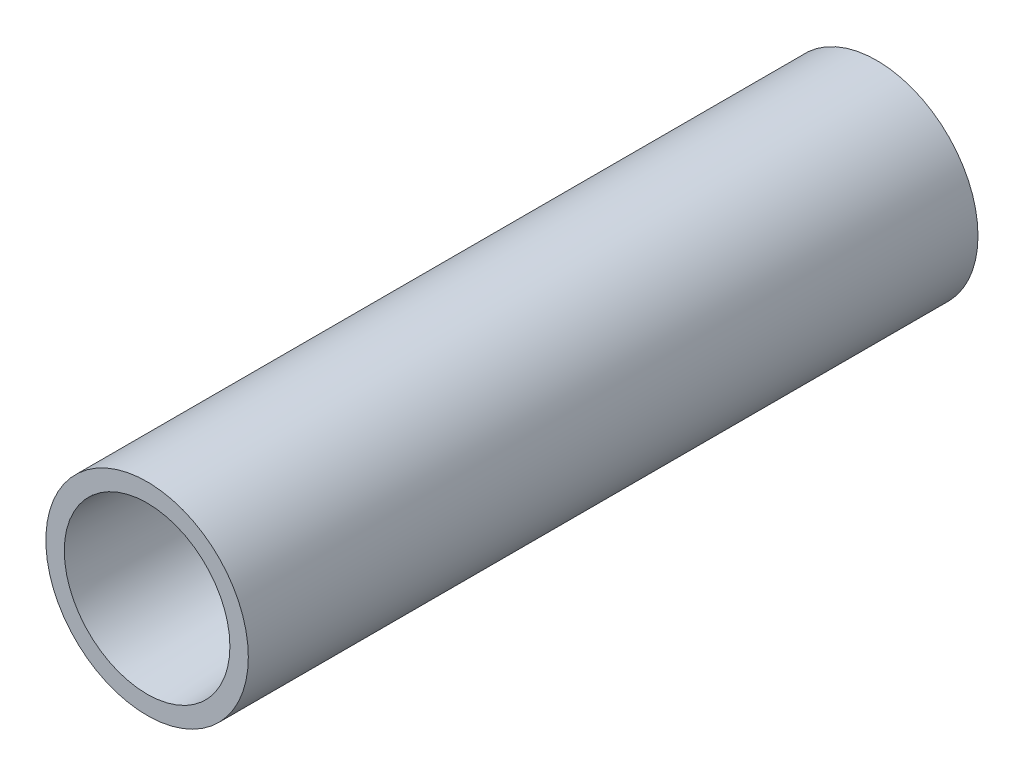
from build123d import *

# Parameters (mm, degrees)
SKETCH1_R           = 2.775
BOSS_EXTRUDE1_DEPTH = 20
SKETCH2_R           = 2.27
CUT_EXTRUDE1_DEPTH  = 5.68
CUT_EXTRUDE1_TAPER  = 3.074
SKETCH7_R           = 1
CUT_EXTRUDE2_DEPTH  = 21
SKETCH9_R           = 2.27
CUT_EXTRUDE3_DEPTH  = 5.68
CUT_EXTRUDE3_TAPER  = 3.074


with BuildPart() as part:
    # Sketch1 → Boss-Extrude1 (new body)
    with BuildSketch(Plane.XY):
        Circle(SKETCH1_R)
    extrude(amount=BOSS_EXTRUDE1_DEPTH)

    # Sketch2 → Cut-Extrude1 (cut)
    with BuildSketch(Plane.XY):
        Circle(SKETCH2_R)
    extrude(amount=CUT_EXTRUDE1_DEPTH, taper=CUT_EXTRUDE1_TAPER, mode=Mode.SUBTRACT)

    # Sketch7 → Cut-Extrude2 (cut, through all)
    with BuildSketch(Plane.XY):
        Circle(SKETCH7_R)
    extrude(amount=CUT_EXTRUDE2_DEPTH, mode=Mode.SUBTRACT)

    # Sketch9 → Cut-Extrude3 (cut)
    with BuildSketch(Plane.XY.offset(20)):
        Circle(SKETCH9_R)
    extrude(amount=-CUT_EXTRUDE3_DEPTH, taper=CUT_EXTRUDE3_TAPER, mode=Mode.SUBTRACT)


solid = part.part
